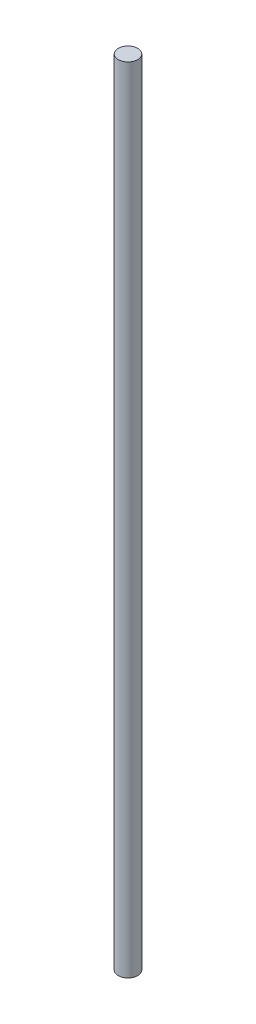
from build123d import *

# Parameters (mm, degrees)
SKETCH1_R           = 4.7625
BOSS_EXTRUDE1_DEPTH = 387.35


with BuildPart() as part:
    # Sketch1 → Boss-Extrude1 (new body)
    with BuildSketch(Plane(origin=(0, 0, 0), x_dir=(1, 0, 0), z_dir=(0, 1, 0))):
        Circle(SKETCH1_R)
    extrude(amount=BOSS_EXTRUDE1_DEPTH)


solid = part.part
